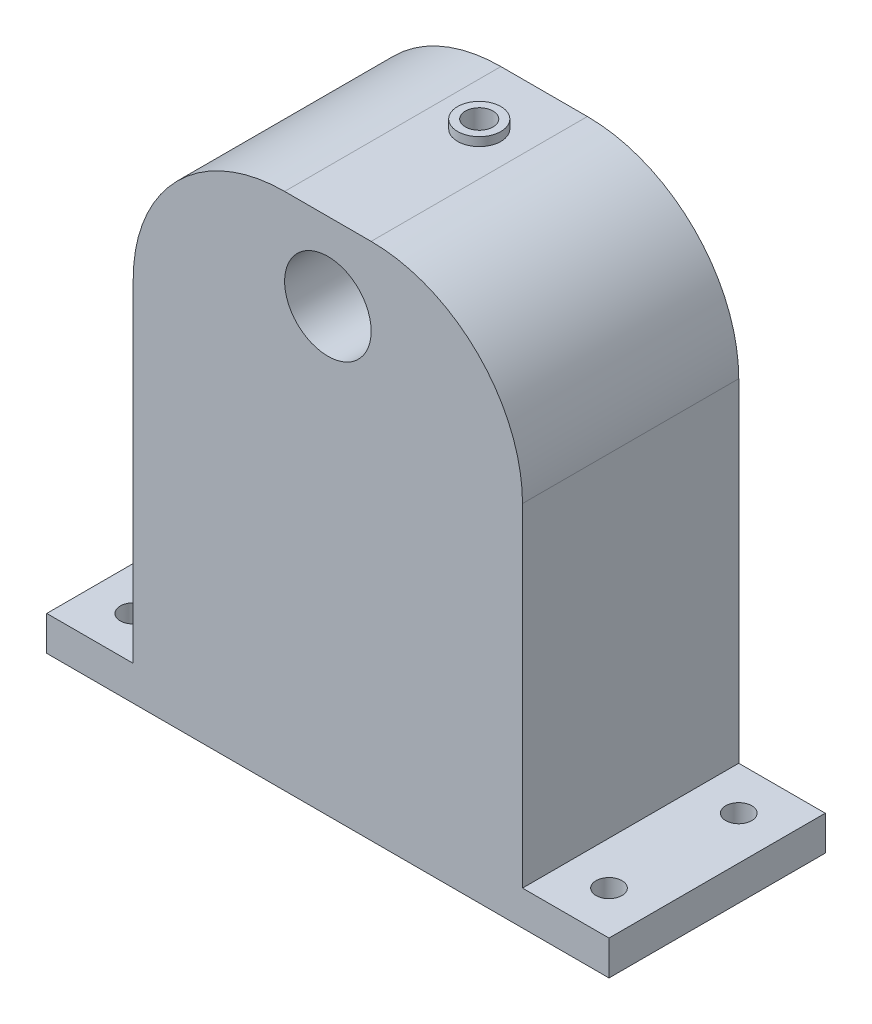
from build123d import *

# Parameters (mm, degrees)
SKETCH1_W           = 65
SKETCH1_H           = 15
BOSS_EXTRUDE1_DEPTH = 4
SKETCH2_W           = 45
SKETCH2_H           = 15
BOSS_EXTRUDE2_DEPTH = 56
SKETCH3_R           = 5
CUT_EXTRUDE1_DEPTH  = 10
CUT_EXTRUDE5_REACH  = 17
BOSS_EXTRUDE3_DEPTH = 10
CUT_EXTRUDE6_REACH  = 6
SKETCH8_R           = 1.5
CUT_EXTRUDE7_DEPTH  = 22.5
SKETCH10_R          = 1.6
BOSS_EXTRUDE4_DEPTH = 20
SKETCH11_R          = 1.6
CUT_EXTRUDE8_DEPTH  = 35
SKETCH12_R          = 2.5
SKETCH12_R_2        = 1.6
BOSS_EXTRUDE5_DEPTH = 1


with BuildPart() as part:
    # Sketch1 → Boss-Extrude1 (new body)
    with BuildSketch(Plane(origin=(0, 0, 0), x_dir=(1, 0, 0), z_dir=(0, 1, 0))):
        Rectangle(SKETCH1_W, SKETCH1_H)
    extrude(amount=BOSS_EXTRUDE1_DEPTH)

    # Sketch2 → Boss-Extrude2 (add)
    with BuildSketch(Plane(origin=(0, 4, 0), x_dir=(1, 0, 0), z_dir=(0, 1, 0))):
        Rectangle(SKETCH2_W, SKETCH2_H)
    extrude(amount=BOSS_EXTRUDE2_DEPTH)

    # Sketch3 → Cut-Extrude1 (cut)
    with BuildSketch(Plane.XY.offset(7.5)):
        with Locations((0, 51)):
            Circle(SKETCH3_R)
    extrude(amount=-CUT_EXTRUDE1_DEPTH, mode=Mode.SUBTRACT)

    # Sketch6 → Cut-Extrude5 (cut, up to next)
    with BuildSketch(Plane.XY.offset(7.5), mode=Mode.PRIVATE) as cut_extrude5_sk1:
        with BuildLine():
            Line((5, 60), (22.5, 60))
            Line((22.5, 60), (22.5, 42.5))
            ThreePointArc((22.5, 42.5), (17.374368671, 54.874368671), (5, 60))
        make_face()
    cut_extrude5_tool1 = extrude(cut_extrude5_sk1.sketch, amount=-CUT_EXTRUDE5_REACH, mode=Mode.PRIVATE) & part.part
    add(cut_extrude5_tool1.solids().sort_by_distance((18.591061, 56.091061, 7.5))[0], mode=Mode.SUBTRACT)
    # Sketch6 → Cut-Extrude5 (cut, up to next)
    with BuildSketch(Plane.XY.offset(7.5), mode=Mode.PRIVATE) as cut_extrude5_sk2:
        with BuildLine():
            Line((-22.5, 42.5), (-22.5, 60))
            Line((-22.5, 60), (-5, 60))
            ThreePointArc((-5, 60), (-17.374368671, 54.874368671), (-22.5, 42.5))
        make_face()
    cut_extrude5_tool2 = extrude(cut_extrude5_sk2.sketch, amount=-CUT_EXTRUDE5_REACH, mode=Mode.PRIVATE) & part.part
    add(cut_extrude5_tool2.solids().sort_by_distance((-18.591061, 56.091061, 7.5))[0], mode=Mode.SUBTRACT)

    # Sketch7 → Boss-Extrude3 (add)
    with BuildSketch(Plane(origin=(0, 0, -7.5), x_dir=(-1, 0, 0), z_dir=(0, 0, -1))):
        with BuildLine():
            Line((-22.5, 42.5), (-22.5, 4))
            Line((-22.5, 4), (-32.5, 4))
            Line((-32.5, 4), (-32.5, 0))
            Line((-32.5, 0), (32.5, 0))
            Line((32.5, 0), (32.5, 4))
            Line((32.5, 4), (22.5, 4))
            Line((22.5, 4), (22.5, 42.5))
            ThreePointArc((22.5, 42.5), (17.374368671, 54.874368671), (5, 60))
            Line((5, 60), (-5, 60))
            ThreePointArc((-5, 60), (-17.374368671, 54.874368671), (-22.5, 42.5))
        make_face()
    extrude(amount=BOSS_EXTRUDE3_DEPTH)

    # Sketch8 → Cut-Extrude6 (cut, up to next)
    with BuildSketch(Plane(origin=(0, 4, 0), x_dir=(1, 0, 0), z_dir=(0, 1, 0)), mode=Mode.PRIVATE) as cut_extrude6_sk1:
        with Locations((-27.5, -2.5)):
            Circle(SKETCH8_R)
    cut_extrude6_tool1 = extrude(cut_extrude6_sk1.sketch, amount=-CUT_EXTRUDE6_REACH, mode=Mode.PRIVATE) & part.part
    add(cut_extrude6_tool1.solids().sort_by_distance((-27.5, 4, 2.5))[0], mode=Mode.SUBTRACT)
    # Sketch8 → Cut-Extrude6 (cut, up to next)
    with BuildSketch(Plane(origin=(0, 4, 0), x_dir=(1, 0, 0), z_dir=(0, 1, 0)), mode=Mode.PRIVATE) as cut_extrude6_sk2:
        with Locations((-27.5, 12.5)):
            Circle(SKETCH8_R)
    cut_extrude6_tool2 = extrude(cut_extrude6_sk2.sketch, amount=-CUT_EXTRUDE6_REACH, mode=Mode.PRIVATE) & part.part
    add(cut_extrude6_tool2.solids().sort_by_distance((-27.5, 4, -12.5))[0], mode=Mode.SUBTRACT)
    # Sketch8 → Cut-Extrude6 (cut, up to next)
    with BuildSketch(Plane(origin=(0, 4, 0), x_dir=(1, 0, 0), z_dir=(0, 1, 0)), mode=Mode.PRIVATE) as cut_extrude6_sk3:
        with Locations((27.5, 12.5)):
            Circle(SKETCH8_R)
    cut_extrude6_tool3 = extrude(cut_extrude6_sk3.sketch, amount=-CUT_EXTRUDE6_REACH, mode=Mode.PRIVATE) & part.part
    add(cut_extrude6_tool3.solids().sort_by_distance((27.5, 4, -12.5))[0], mode=Mode.SUBTRACT)
    # Sketch8 → Cut-Extrude6 (cut, up to next)
    with BuildSketch(Plane(origin=(0, 4, 0), x_dir=(1, 0, 0), z_dir=(0, 1, 0)), mode=Mode.PRIVATE) as cut_extrude6_sk4:
        with Locations((27.5, -2.5)):
            Circle(SKETCH8_R)
    cut_extrude6_tool4 = extrude(cut_extrude6_sk4.sketch, amount=-CUT_EXTRUDE6_REACH, mode=Mode.PRIVATE) & part.part
    add(cut_extrude6_tool4.solids().sort_by_distance((27.5, 4, 2.5))[0], mode=Mode.SUBTRACT)

    # Sketch9 → Cut-Extrude7 (cut)
    with BuildSketch(Plane(origin=(0, 60, 0), x_dir=(1, 0, 0), z_dir=(0, 1, 0))):
        Polygon((-2.875, 11.659882024), (-2.875, 17.5), (2.875, 17.5), (2.875, 11.659882024), (2.875, 8.340117976), (0, 6.680235952), (-2.875, 8.340117976), align=None)
    extrude(amount=-CUT_EXTRUDE7_DEPTH, mode=Mode.SUBTRACT)

    # Sketch10 → Boss-Extrude4 (add)
    with BuildSketch(Plane(origin=(0, 60, 0), x_dir=(1, 0, 0), z_dir=(0, 1, 0))):
        Polygon((0, 6.680235952), (2.875, 8.340117976), (2.875, 17.5), (-2.875, 17.5), (-2.875, 8.340117976), align=None)
        with Locations((0, 10)):
            Circle(SKETCH10_R, mode=Mode.SUBTRACT)
    extrude(amount=-BOSS_EXTRUDE4_DEPTH)

    # Sketch11 → Cut-Extrude8 (cut)
    with BuildSketch(Plane(origin=(0, 60, 0), x_dir=(1, 0, 0), z_dir=(0, 1, 0))):
        with Locations((0, 10)):
            Circle(SKETCH11_R)
    extrude(amount=-CUT_EXTRUDE8_DEPTH, mode=Mode.SUBTRACT)

    # Sketch12 → Boss-Extrude5 (add)
    with BuildSketch(Plane(origin=(0, 60, 0), x_dir=(1, 0, 0), z_dir=(0, 1, 0))):
        with Locations((0, 10)):
            Circle(SKETCH12_R)
        with Locations((0, 10)):
            Circle(SKETCH12_R_2, mode=Mode.SUBTRACT)
    extrude(amount=BOSS_EXTRUDE5_DEPTH)


solid = part.part
